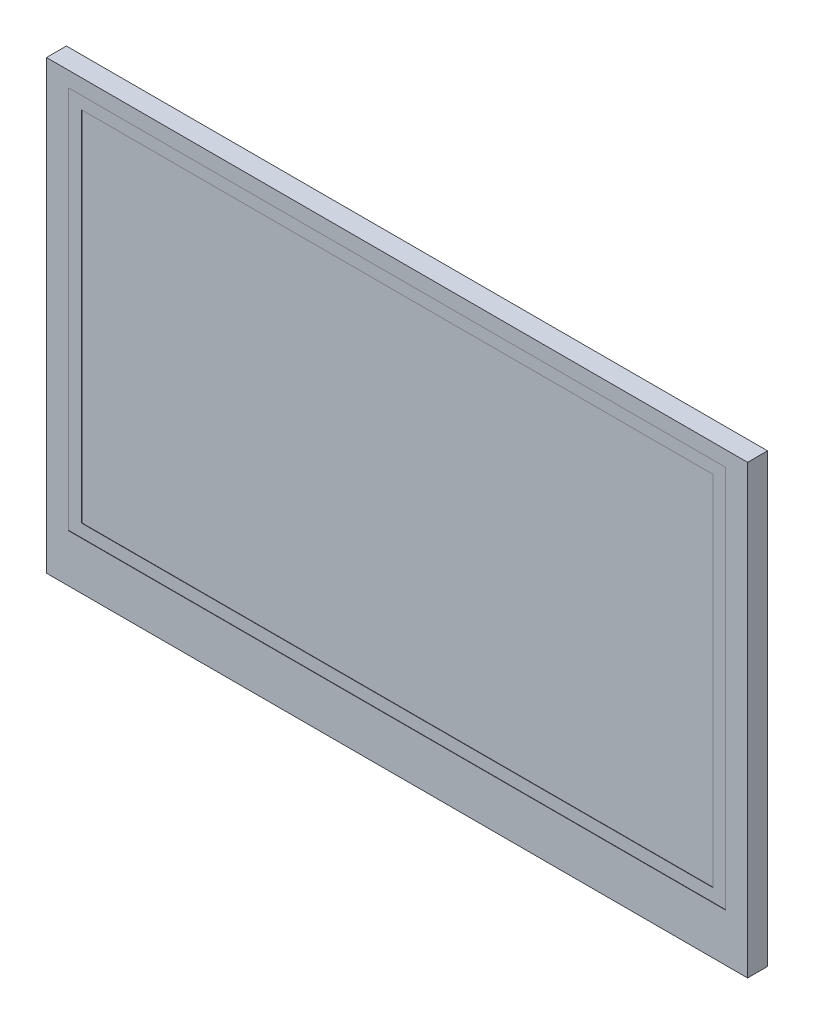
from build123d import *

# Parameters (mm, degrees)
SKETCH1_W           = 105.5
SKETCH1_H           = 67.2
SKETCH1_W_2         = 98.9
SKETCH1_H_2         = 57.7
BOSS_EXTRUDE1_DEPTH = 3
SKETCH1_3_W         = 98.9
SKETCH1_3_H         = 57.7
SKETCH1_3_W_2       = 95.04
SKETCH1_3_H_2       = 53.856
BOSS_EXTRUDE2_DEPTH = 2.95
SKETCH1_4_W         = 95.04
SKETCH1_4_H         = 53.856
BOSS_EXTRUDE3_DEPTH = 2.9


with BuildPart() as part:
    # Sketch1 → Boss-Extrude1 (new body)
    with BuildSketch(Plane.XY):
        Rectangle(SKETCH1_W, SKETCH1_H)
        with Locations((0, 2.45)):
            Rectangle(SKETCH1_W_2, SKETCH1_H_2, mode=Mode.SUBTRACT)
    extrude(amount=BOSS_EXTRUDE1_DEPTH)

    # Sketch1_3 → Boss-Extrude2 (add)
    with BuildSketch(Plane.XY):
        with Locations((0, 2.45)):
            Rectangle(SKETCH1_3_W, SKETCH1_3_H)
        with Locations((0, 2.452)):
            Rectangle(SKETCH1_3_W_2, SKETCH1_3_H_2, mode=Mode.SUBTRACT)
    extrude(amount=BOSS_EXTRUDE2_DEPTH)

    # Sketch1_4 → Boss-Extrude3 (add)
    with BuildSketch(Plane.XY):
        with Locations((0, 2.452)):
            Rectangle(SKETCH1_4_W, SKETCH1_4_H)
    extrude(amount=BOSS_EXTRUDE3_DEPTH)


solid = part.part
